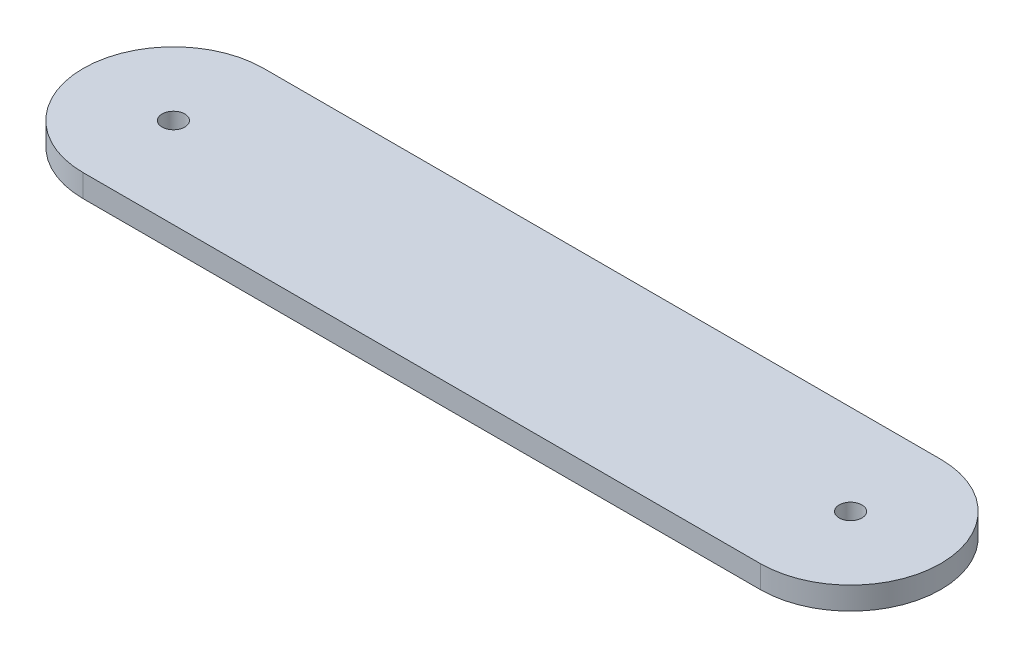
from build123d import *

# Parameters (mm, degrees)
BOSS_EXTRUDE1_DEPTH  = 3.175
M3_CLEARANCE_HOLE1_D = 3.2


with BuildPart() as part:
    # Sketch1 → Boss-Extrude1 (new body)
    with BuildSketch(Plane(origin=(0, 0, 0), x_dir=(1, 0, 0), z_dir=(0, 1, 0))):
        with BuildLine():
            Line((-47.625, 12.7), (47.625, 12.7))
            ThreePointArc((47.625, 12.7), (60.325, 0), (47.625, -12.7))
            Line((47.625, -12.7), (-47.625, -12.7))
            ThreePointArc((-47.625, -12.7), (-60.325, 0), (-47.625, 12.7))
        make_face()
    extrude(amount=BOSS_EXTRUDE1_DEPTH)

    # M3 Clearance Hole1 (through all)
    with Locations(Plane(origin=(0, 3.175, 0), x_dir=(1, 0, 0), z_dir=(0, 1, 0))):
        with Locations((-47.625, 0), (47.625, 0)):
            Hole(M3_CLEARANCE_HOLE1_D / 2)


solid = part.part
